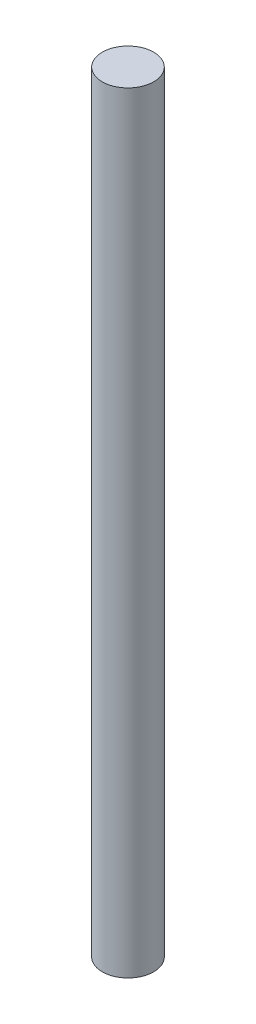
from build123d import *

# Parameters (mm, degrees)
SKETCH1_R           = 3.81
BOSS_EXTRUDE1_DEPTH = 114.3


with BuildPart() as part:
    # Sketch1 → Boss-Extrude1 (new body)
    with BuildSketch(Plane(origin=(0, 0, 0), x_dir=(1, 0, 0), z_dir=(0, 1, 0))):
        Circle(SKETCH1_R)
    extrude(amount=BOSS_EXTRUDE1_DEPTH)


solid = part.part
